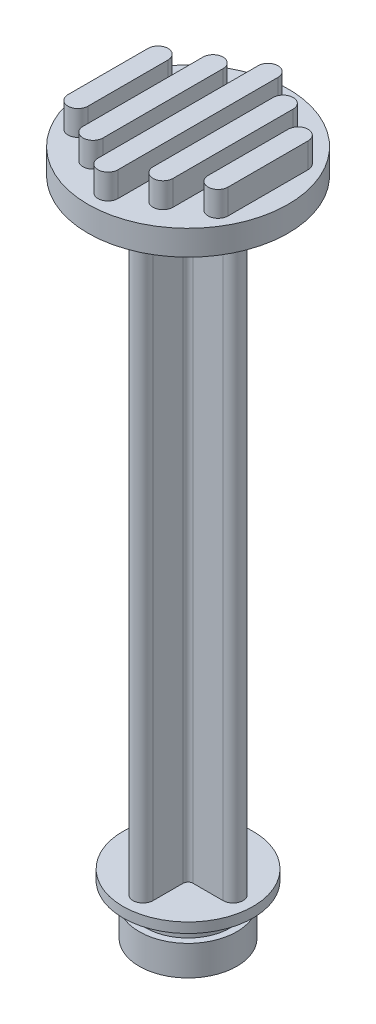
from build123d import *

# Parameters (mm, degrees)
BOSS_EXTRUDE1_DEPTH = 60
SKETCH3_R           = 10
BOSS_EXTRUDE2_DEPTH = 2.5
BOSS_EXTRUDE3_DEPTH = 2.5


with BuildPart() as part:
    # Sketch1 → Revolve1 (revolve)
    with BuildSketch(Plane.XY):
        Polygon((0, 0), (4.875, 0), (4.875, 3), (4.225, 3), (4.225, 5), (6.5, 5), (6.5, 6), (0, 6), align=None)
    revolve(axis=Axis((0, 6, 0), (0, -1, 0)))

    # Sketch2 → Boss-Extrude1 (add)
    with BuildSketch(Plane(origin=(0, 6, 0), x_dir=(1, 0, 0), z_dir=(0, 1, 0))):
        with BuildLine():
            Line((-1, 4.5), (-1, 1.5))
            ThreePointArc((-1, 1.5), (-1.146446609, 1.146446609), (-1.5, 1))
            Line((-1.5, 1), (-4.5, 1))
            ThreePointArc((-4.5, 1), (-5.5, 0), (-4.5, -1))
            Line((-4.5, -1), (-1.5, -1))
            ThreePointArc((-1.5, -1), (-1.146446609, -1.146446609), (-1, -1.5))
            Line((-1, -1.5), (-1, -4.5))
            ThreePointArc((-1, -4.5), (0, -5.5), (1, -4.5))
            Line((1, -4.5), (1, -1.5))
            ThreePointArc((1, -1.5), (1.146446609, -1.146446609), (1.5, -1))
            Line((1.5, -1), (4.5, -1))
            ThreePointArc((4.5, -1), (5.5, 0), (4.5, 1))
            Line((4.5, 1), (1.5, 1))
            ThreePointArc((1.5, 1), (1.146446609, 1.146446609), (1, 1.5))
            Line((1, 1.5), (1, 4.5))
            ThreePointArc((1, 4.5), (0, 5.5), (-1, 4.5))
        make_face()
    extrude(amount=BOSS_EXTRUDE1_DEPTH)

    # Sketch3 → Boss-Extrude2 (add)
    with BuildSketch(Plane(origin=(0, 66, 0), x_dir=(1, 0, 0), z_dir=(0, 1, 0))):
        Circle(SKETCH3_R)
    extrude(amount=BOSS_EXTRUDE2_DEPTH)

    # Sketch4 → Boss-Extrude3 (add)
    with BuildSketch(Plane(origin=(0, 68.5, 0), x_dir=(1, 0, 0), z_dir=(0, 1, 0))):
        with BuildLine():
            ThreePointArc((1, 8), (0, 9), (-1, 8))
            Line((-1, 8), (-1, -8))
            ThreePointArc((-1, -8), (0, -9), (1, -8))
            Line((1, -8), (1, 8))
        make_face()
        with BuildLine():
            ThreePointArc((-2.5, 6), (-3.5, 7), (-4.5, 6))
            Line((-4.5, 6), (-4.5, -6))
            ThreePointArc((-4.5, -6), (-3.5, -7), (-2.5, -6))
            Line((-2.5, -6), (-2.5, 6))
        make_face()
        with BuildLine():
            ThreePointArc((4.5, 6), (3.5, 7), (2.5, 6))
            Line((2.5, 6), (2.5, -6))
            ThreePointArc((2.5, -6), (3.5, -7), (4.5, -6))
            Line((4.5, -6), (4.5, 6))
        make_face()
        with BuildLine():
            ThreePointArc((6, 4), (7, 5), (8, 4))
            Line((8, 4), (8, -4))
            ThreePointArc((8, -4), (7, -5), (6, -4))
            Line((6, -4), (6, 4))
        make_face()
        with BuildLine():
            Line((-6, -4), (-6, 4))
            ThreePointArc((-6, 4), (-7, 5), (-8, 4))
            Line((-8, 4), (-8, -4))
            ThreePointArc((-8, -4), (-7, -5), (-6, -4))
        make_face()
    extrude(amount=BOSS_EXTRUDE3_DEPTH)


solid = part.part
